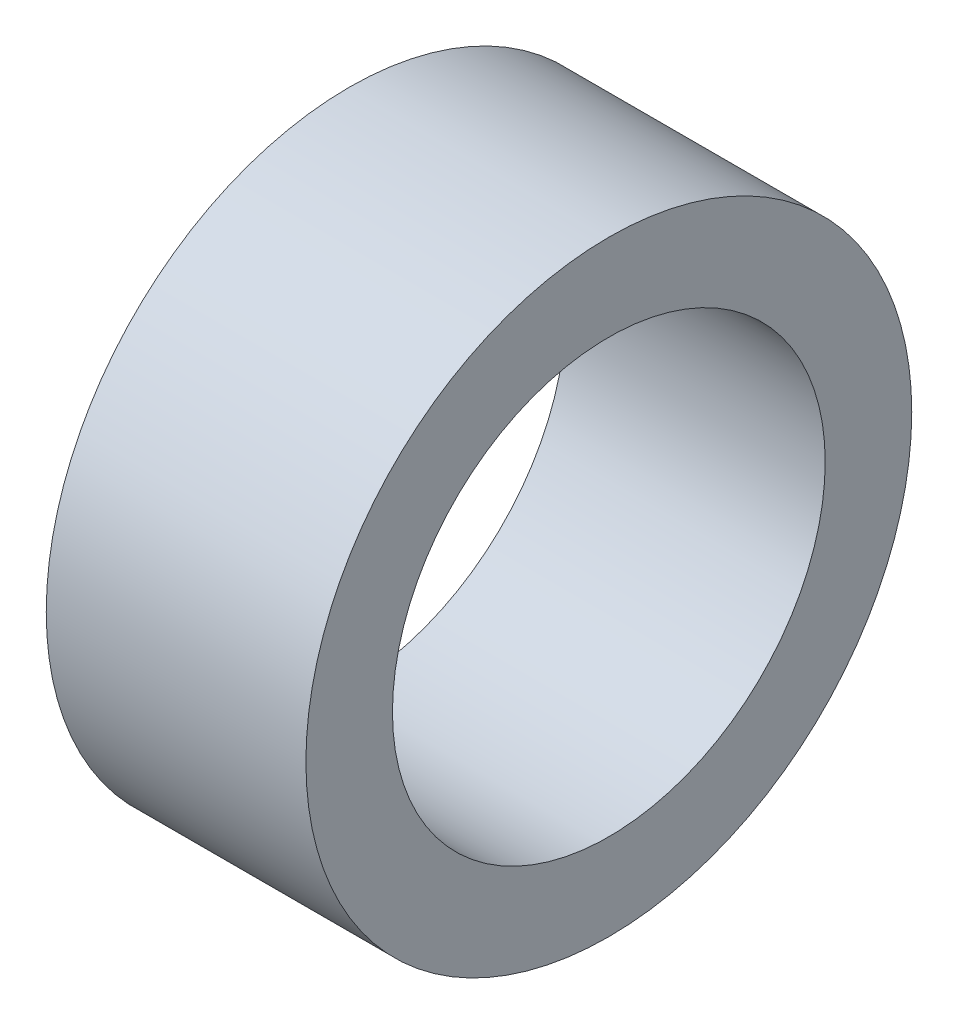
from build123d import *

# Parameters (mm, degrees)
SKETCH_1_R      = 7
SKETCH_1_R_2    = 5
EXTRUDE_1_DEPTH = 6


with BuildPart() as part:
    # 草图1 → 凸台-拉伸1 (new body)
    with BuildSketch(Plane(origin=(0, 0, 0), x_dir=(0, 0, -1), z_dir=(1, 0, 0))):
        Circle(SKETCH_1_R)
        Circle(SKETCH_1_R_2, mode=Mode.SUBTRACT)
    extrude(amount=EXTRUDE_1_DEPTH)


solid = part.part
